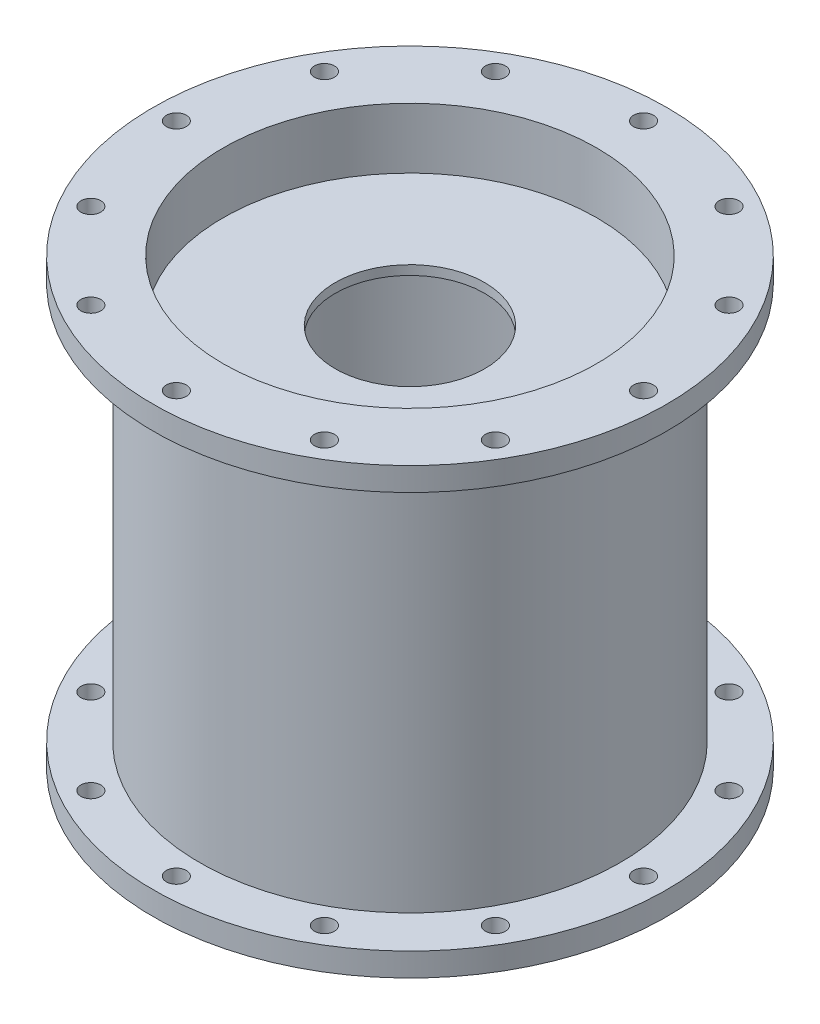
from build123d import *

# Parameters (mm, degrees)
SKETCH4_W                  = 30.48
SKETCH4_H                  = 2.54
F_3_0_213_DIAMETER_HOLE2_D = 5.4102


with BuildPart() as part:
    # Sketch1 → Chamber (revolve)
    with BuildSketch(Plane(origin=(0, 0, 0), x_dir=(0, 0, -1), z_dir=(1, 0, 0))):
        Polygon((57.15, 6.35), (57.15, 114.3), (69.85, 114.3), (69.85, 120.65), (57.15, 120.65), (50.8, 120.65), (50.8, 114.3), (50.8, 6.35), (50.8, 0), (57.15, 0), (69.85, 0), (69.85, 6.35), align=None)
    revolve(axis=Axis((0, 0, 0), (0, 1, 0)))

    # Sketch4 → Turbulence Rings (revolve)
    with BuildSketch(Plane(origin=(0, 0, 0), x_dir=(0, 0, -1), z_dir=(1, 0, 0))):
        with Locations((35.56, 102.931657822)):
            Rectangle(SKETCH4_W, SKETCH4_H)
        with Locations((35.56, 17.718342178)):
            Rectangle(SKETCH4_W, SKETCH4_H)
    revolve(axis=Axis((0, 0, 0), (0, 1, 0)))

    # #3 (0.213) Diameter Hole2 (through all)
    with Locations(Plane(origin=(0, 120.65, 0), x_dir=(1, 0, 0), z_dir=(0, 1, 0))):
        with Locations((0, 0), (-63.5, 0), (-54.99261314, 31.75), (-31.75, 54.99261314), (0, 63.5), (31.75, 54.99261314), (54.99261314, 31.75), (63.5, 0), (54.99261314, -31.75), (31.75, -54.99261314), (0, -63.5), (-31.75, -54.99261314), (-54.99261314, -31.75)):
            Hole(F_3_0_213_DIAMETER_HOLE2_D / 2)


solid = part.part
